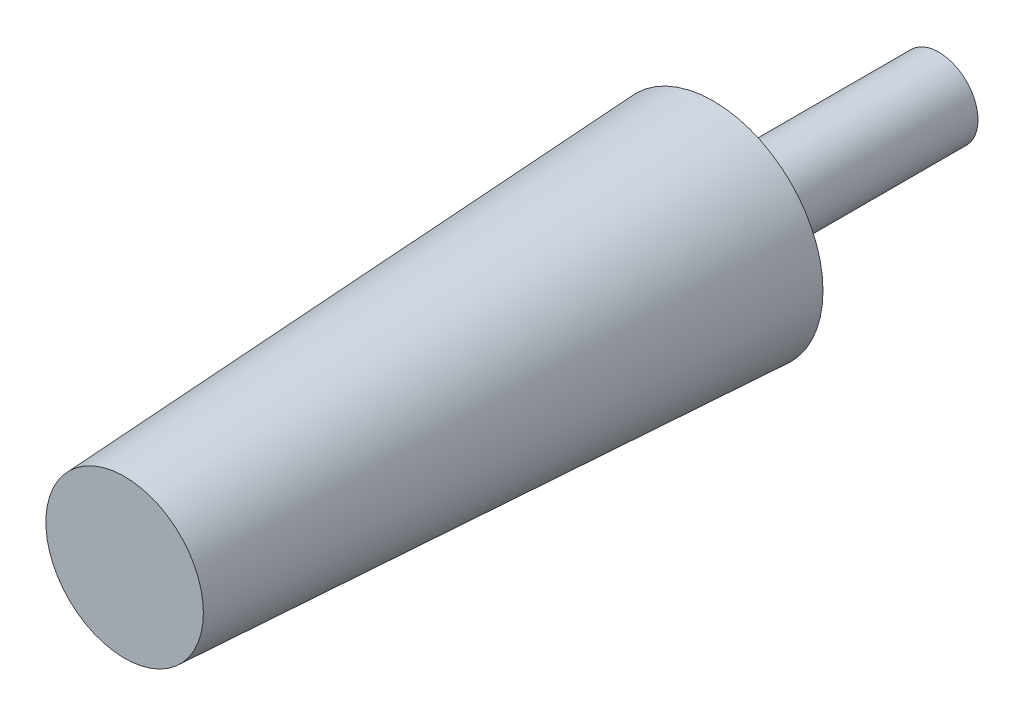
from build123d import *

# Parameters (mm, degrees)
SKETCH3_R           = 3.96875
BOSS_EXTRUDE1_DEPTH = 22.86
SKETCH4_R           = 11.1125
BOSS_EXTRUDE2_DEPTH = 59.69
BOSS_EXTRUDE2_TAPER = 3


with BuildPart() as part:
    # Sketch3 → Boss-Extrude1 (new body)
    with BuildSketch(Plane.XY):
        Circle(SKETCH3_R)
    extrude(amount=BOSS_EXTRUDE1_DEPTH)

    # Sketch4 → Boss-Extrude2 (add)
    with BuildSketch(Plane.XY.offset(22.86)):
        Circle(SKETCH4_R)
    extrude(amount=BOSS_EXTRUDE2_DEPTH, taper=BOSS_EXTRUDE2_TAPER)


solid = part.part
